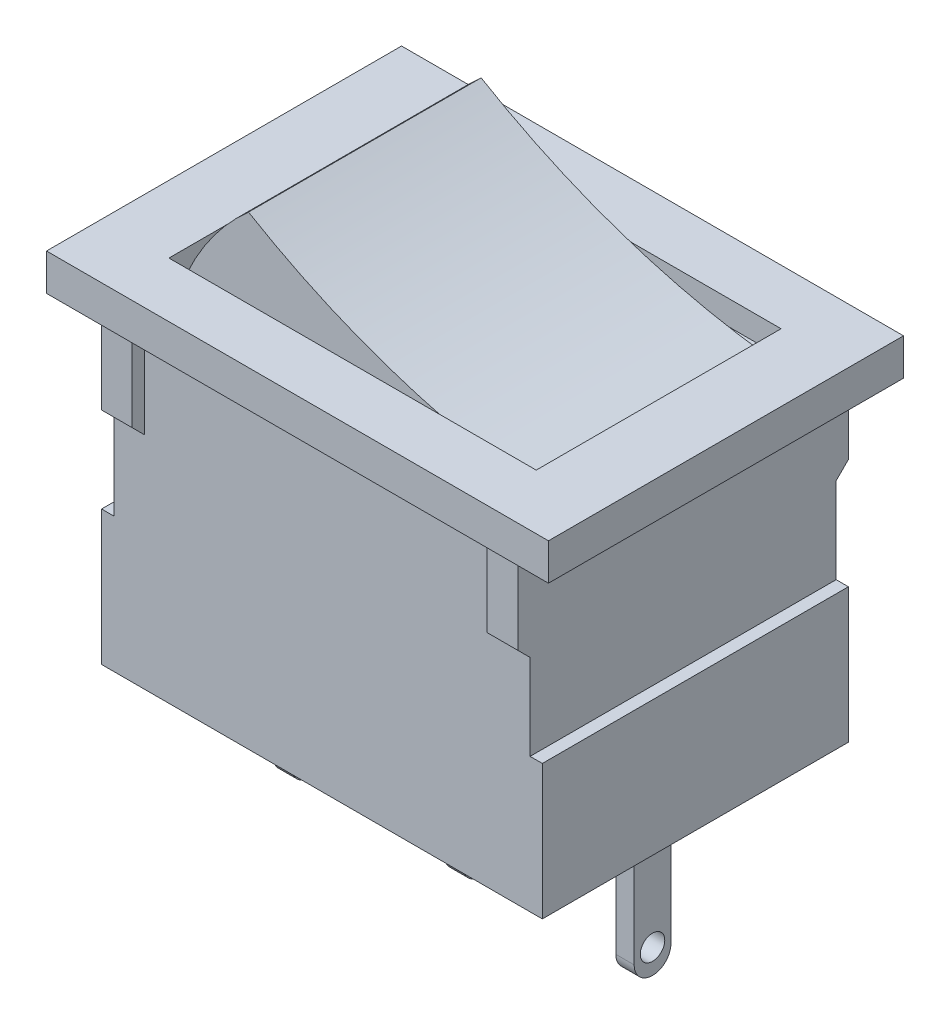
from build123d import *

# Parameters (mm, degrees)
SKETCH_1_W             = 18
SKETCH_1_H             = 11
EXTRUDE_1_DEPTH        = 12.5
SKETCH_2_W             = 20.5
SKETCH_2_H             = 14.5
EXTRUDE_2_DEPTH        = 1.5
SKETCH_3_W             = 0.5
SKETCH_3_H             = 7.5
CUT_EXTRUDE_2_DEPTH    = 14.5
EXTRUDE_3_DEPTH        = 1.25
MIRROR_2_COPY_1_DEPTH  = 1.25
SKETCH_7_W             = 18
SKETCH_7_H             = 12.5
EXTRUDE_4_DEPTH        = 2
SKETCH_8_W             = 15
SKETCH_8_H             = 10
CUT_EXTRUDE_3_DEPTH    = 1
EXTRUDE_5_DEPTH        = 4.75
EXTRUDE_5_DEPTH_BACK   = 4.75
SKETCH_11_R            = 0.5
EXTRUDE_6_DEPTH        = 0.75
PATTERN_LINEAR_1_COUNT = 3
PATTERN_LINEAR_1_PITCH = 7


with BuildPart() as part:
    # Эскиз1 → Бобышка-Вытянуть1 (new body)
    with BuildSketch(Plane.XY):
        with Locations((9, 5.5)):
            Rectangle(SKETCH_1_W, SKETCH_1_H)
    extrude(amount=EXTRUDE_1_DEPTH)

    # Эскиз2 → Бобышка-Вытянуть2 (add)
    with BuildSketch(Plane(origin=(0, 11, 0), x_dir=(1, 0, 0), z_dir=(0, 1, 0))):
        with Locations((9, -6.25)):
            Rectangle(SKETCH_2_W, SKETCH_2_H)
    extrude(amount=EXTRUDE_2_DEPTH)

    # Эскиз3 → Вырез-Вытянуть2 (cut, through all)
    with BuildSketch(Plane.XY.offset(12.5)):
        with Locations((17.75, 7.25)):
            Rectangle(SKETCH_3_W, SKETCH_3_H)
        with Locations((0.25, 7.25)):
            Rectangle(SKETCH_3_W, SKETCH_3_H)
    extrude(amount=-CUT_EXTRUDE_2_DEPTH, mode=Mode.SUBTRACT)

    # Эскиз4 → Бобышка-Вытянуть3 (add)
    with BuildSketch(Plane(origin=(17.5, 0, 0), x_dir=(0, 0, -1), z_dir=(1, 0, 0))):
        Polygon((-12.5, 7), (-13, 7.5), (-13, 11), (-12.5, 11), align=None)
    extrude_3 = extrude(amount=-EXTRUDE_3_DEPTH)

    # Зеркальное отражение1: Бобышка-Вытянуть3 across plane
    add(extrude_3.mirror(Plane(origin=(0, 0, 6.25), x_dir=(1, 0, 0), z_dir=(0, 0, -1))))

    # Зеркальное отражение2: Бобышка-Вытянуть3 across plane
    add(extrude_3.mirror(Plane.ZY.offset(-9)))

    # Зеркальное отражение2 copy 1 sketch → Зеркальное отражение2 copy 1 (add)
    with BuildSketch(Plane(origin=(0.5, 0, 12.5), x_dir=(0, 0, 1), z_dir=(-1, 0, 0))):
        Polygon((-12.5, 7), (-13, 7.5), (-13, 11), (-12.5, 11), align=None)
    extrude(amount=-MIRROR_2_COPY_1_DEPTH)

    # Эскиз7 → Бобышка-Вытянуть4 (add)
    with BuildSketch(Plane.XZ):
        with Locations((9, 6.25)):
            Rectangle(SKETCH_7_W, SKETCH_7_H)
    extrude(amount=EXTRUDE_4_DEPTH)

    # Эскиз8 → Вырез-Вытянуть3 (cut)
    with BuildSketch(Plane(origin=(0, 12.5, 0), x_dir=(1, 0, 0), z_dir=(0, 1, 0))):
        with Locations((9, -6.25)):
            Rectangle(SKETCH_8_W, SKETCH_8_H)
    extrude(amount=-CUT_EXTRUDE_3_DEPTH, mode=Mode.SUBTRACT)

    # Эскиз9 → Бобышка-Вытянуть5 (add, two sides)
    with BuildSketch(Plane.YX.offset(-6.25)) as extrude_5_sk:
        with BuildLine():
            Line((11.5, 1.75), (11.5, 16.25))
            ThreePointArc((11.5, 16.25), (12.885675396, 10.16586822), (15.5, 4.5))
            ThreePointArc((15.5, 4.5), (13.669392877, 2.87861036), (11.5, 1.75))
        make_face()
    extrude(amount=EXTRUDE_5_DEPTH)
    extrude(extrude_5_sk.sketch, amount=-EXTRUDE_5_DEPTH_BACK)

    # Эскиз11 → Бобышка-Вытянуть6 (add)
    with BuildSketch(Plane(origin=(1.5, 0, 0), x_dir=(0, 0, 1), z_dir=(1, 0, 0))):
        with BuildLine():
            Line((5.5, 2), (5.5, 7.25))
            ThreePointArc((5.5, 7.25), (5.719669914, 7.780330086), (6.25, 8))
            ThreePointArc((6.25, 8), (6.780330086, 7.780330086), (7, 7.25))
            Line((7, 7.25), (7, 2))
            Line((7, 2), (5.5, 2))
        make_face()
        with Locations((6.25, 7)):
            Circle(SKETCH_11_R, mode=Mode.SUBTRACT)
    extrude_6 = extrude(amount=EXTRUDE_6_DEPTH)

    # Линейный массив1: Бобышка-Вытянуть6 ×3
    with Locations(*[(i * PATTERN_LINEAR_1_PITCH, 0, 0) for i in range(1, PATTERN_LINEAR_1_COUNT)]):
        add(extrude_6)


solid = part.part
